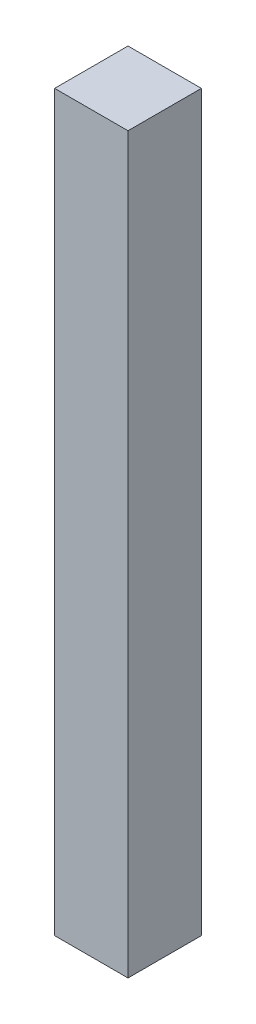
from build123d import *

# Parameters (mm, degrees)
SKETCH1_W           = 100
SKETCH1_H           = 100
BOSS_EXTRUDE1_DEPTH = 1000


with BuildPart() as part:
    # Sketch1 → Boss-Extrude1 (new body)
    with BuildSketch(Plane(origin=(0, 0, 0), x_dir=(1, 0, 0), z_dir=(0, 1, 0))):
        with Locations((50, 50)):
            Rectangle(SKETCH1_W, SKETCH1_H)
    extrude(amount=BOSS_EXTRUDE1_DEPTH)


solid = part.part
